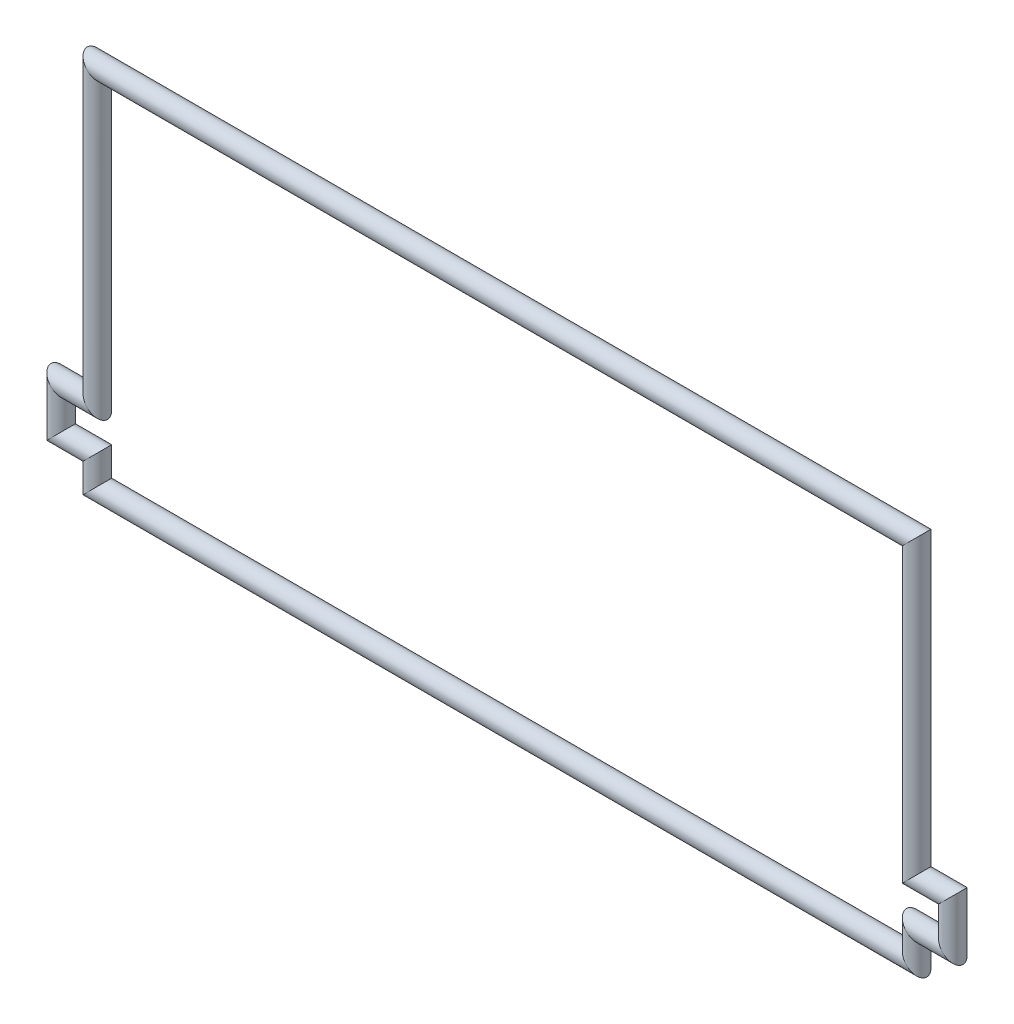
from build123d import *

# Parameters (mm, degrees)
SKETCH2_R = 0.7


with BuildPart() as part:
    # Sweep1: sweep along a path in Sketch1
    with BuildLine(Plane.XY) as sweep1_path:
        Line((0, 25.2), (56.5, 25.2))
        Line((56.5, 25.2), (56.5, 5.05))
        Line((56.5, 5.05), (59, 5.05))
        Line((59, 5.05), (59, 2))
        Line((59, 2), (56.5, 2))
        Line((56.5, 2), (56.5, 0))
        Line((56.5, 0), (0, 0))
        Line((0, 0), (0, 2))
        Line((0, 2), (-2.5, 2))
        Line((-2.5, 2), (-2.5, 5.05))
        Line((-2.5, 5.05), (0, 5.05))
        Line((0, 5.05), (0, 25.2))
    # Sketch2 → Sweep1 (sweep)
    with BuildSketch(Plane(origin=(0, 0, 0), x_dir=(0, 0, -1), z_dir=(1, 0, 0))):
        Circle(SKETCH2_R)
    sweep(path=sweep1_path.line, transition=Transition.RIGHT)


solid = part.part
